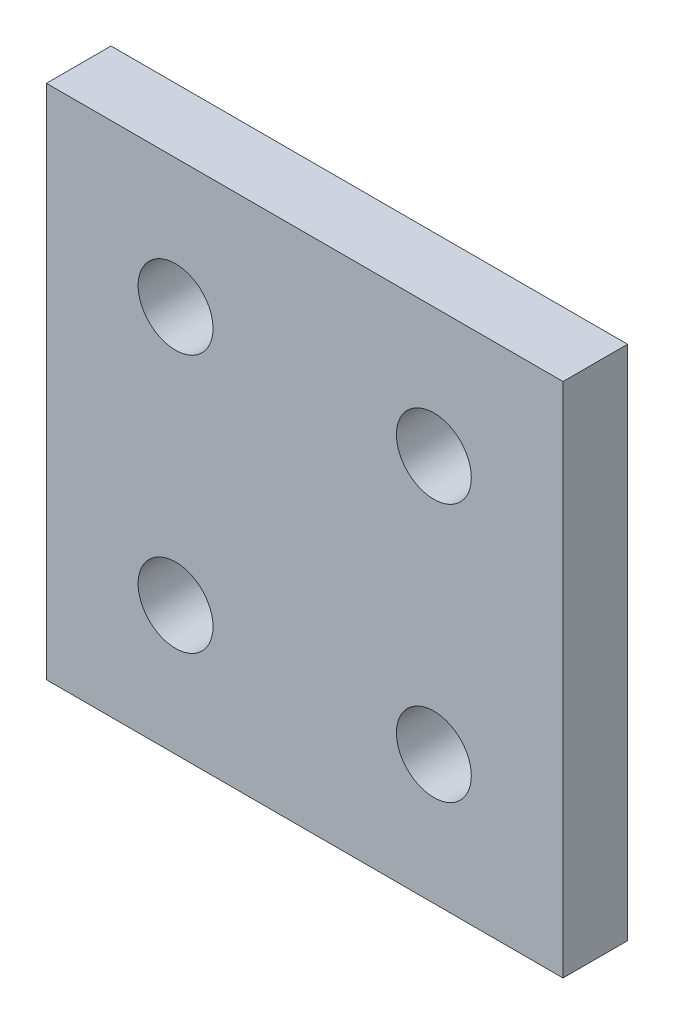
from build123d import *

# Parameters (mm, degrees)
SKETCH1_W            = 40
SKETCH1_H            = 40
BOSS_EXTRUDE1_DEPTH  = 5
M5_CLEARANCE_HOLE1_D = 5.8


with BuildPart() as part:
    # Sketch1 → Boss-Extrude1 (new body)
    with BuildSketch(Plane.XY):
        with Locations((20, 20)):
            Rectangle(SKETCH1_W, SKETCH1_H)
    extrude(amount=BOSS_EXTRUDE1_DEPTH)

    # M5 Clearance Hole1 (through all)
    with Locations(Plane.XY.offset(5)):
        with Locations((10, 30), (30, 30), (30, 10), (10, 10)):
            Hole(M5_CLEARANCE_HOLE1_D / 2)


solid = part.part
